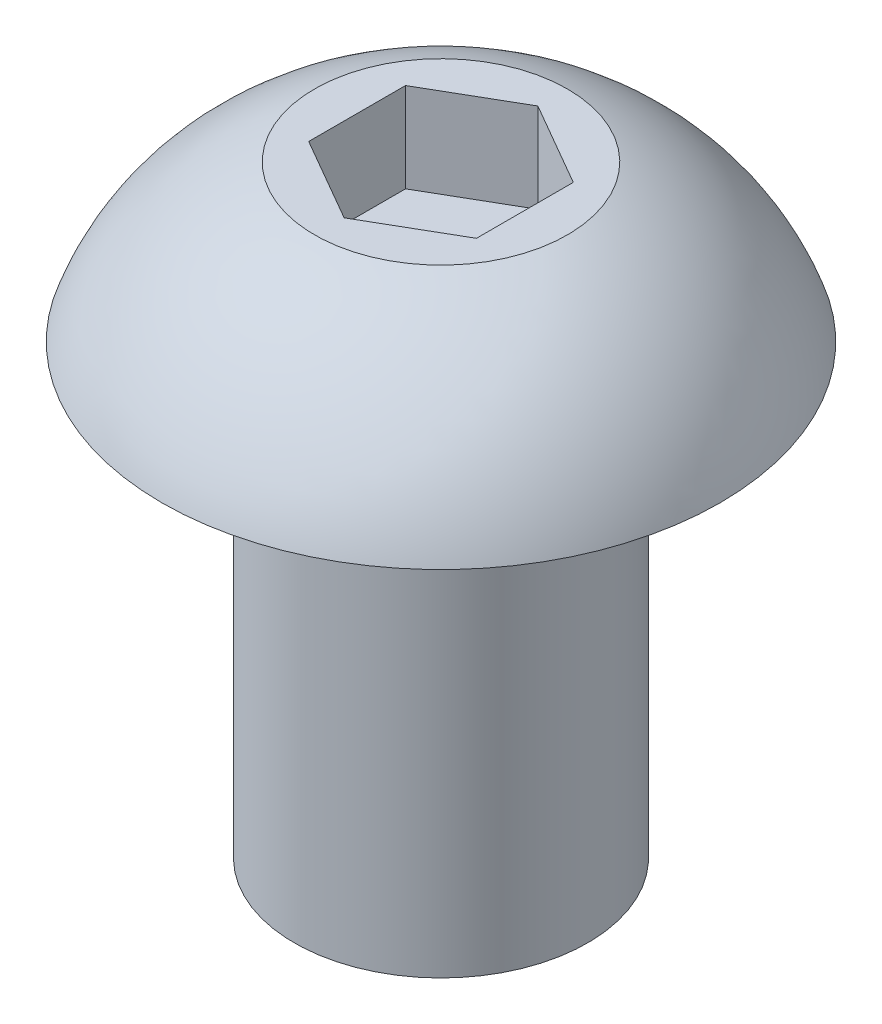
from build123d import *

# Parameters (mm, degrees)
CUT_EXTRUDE1_DEPTH = 1.27


with BuildPart() as part:
    # Sketch1 → Revolve1 (revolve)
    with BuildSketch(Plane.XY):
        with BuildLine():
            Line((-2.0828, 0), (-3.9624, 0))
            ThreePointArc((-3.9624, 0), (-3.131232795, 1.352726455), (-1.79477003, 2.2098))
            Line((-1.79477003, 2.2098), (0, 2.2098))
            Line((0, 2.2098), (0, -6.35))
            Line((0, -6.35), (-2.0828, -6.35))
            Line((-2.0828, -6.35), (-2.0828, 0))
        make_face()
    revolve(axis=Axis((0, -6.35, 0), (0, 1, 0)))

    # Sketch2 → Cut-Extrude1 (cut)
    with BuildSketch(Plane(origin=(0, 2.2098, 0), x_dir=(1, 0, 0), z_dir=(0, 1, 0))):
        Polygon((-1.190625, 0.687407664), (-1.190625, -0.687407664), (0, -1.374815329), (1.190625, -0.687407664), (1.190625, 0.687407664), (0, 1.374815329), align=None)
    extrude(amount=-CUT_EXTRUDE1_DEPTH, mode=Mode.SUBTRACT)


solid = part.part
